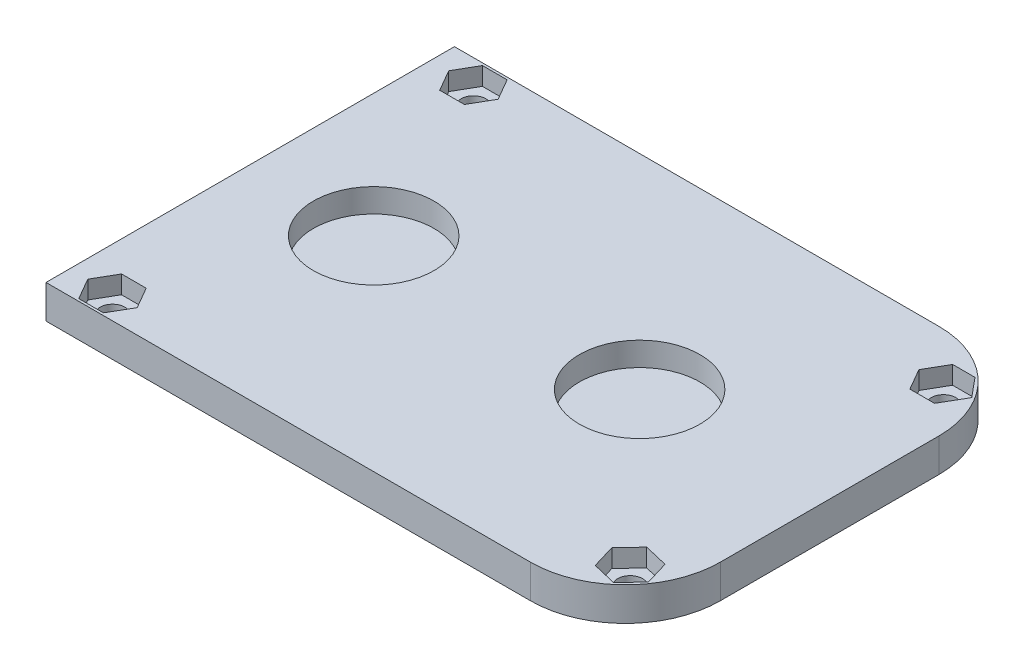
from build123d import *

# Parameters (mm, degrees)
BOSS_EXTRUDE1_DEPTH = 4.476
CUT_EXTRUDE1_DEPTH  = 2.413
SKETCH4_R           = 1.65
CUT_EXTRUDE2_DEPTH  = 5.476
CUT_EXTRUDE3_DEPTH  = 3.175
SKETCH6_W           = 16.984037314
SKETCH6_H           = 62.559907231
CUT_EXTRUDE4_DEPTH  = 5.476


with BuildPart() as part:
    # Sketch1 → Boss-Extrude1 (new body)
    with BuildSketch(Plane(origin=(0, 0, 0), x_dir=(1, 0, 0), z_dir=(0, 1, 0))):
        with BuildLine():
            Line((-8.37964191, 28.608687003), (58.93035809, 28.608687003))
            ThreePointArc((58.93035809, 28.608687003), (67.910614211, 24.888943124), (71.63035809, 15.908687003))
            Line((71.63035809, 15.908687003), (71.63035809, -13.301312997))
            ThreePointArc((71.63035809, -13.301312997), (67.910614211, -22.281569118), (58.93035809, -26.001312997))
            Line((58.93035809, -26.001312997), (-8.37964191, -26.001312997))
            ThreePointArc((-8.37964191, -26.001312997), (-12.86976997, -24.141441058), (-14.72964191, -19.651312997))
            Line((-14.72964191, -19.651312997), (-14.72964191, 22.258687003))
            ThreePointArc((-14.72964191, 22.258687003), (-12.86976997, 26.748815063), (-8.37964191, 28.608687003))
        make_face()
    extrude(amount=BOSS_EXTRUDE1_DEPTH)

    # Sketch2 → Cut-Extrude1 (cut)
    with BuildSketch(Plane(origin=(0, 4.476, 0), x_dir=(1, 0, 0), z_dir=(0, 1, 0))):
        Polygon((64.265579696, 19.401187003), (67.565136484, 19.401187003), (69.384674475, 22.552719249), (67.257293816, 25.116187003), (64.265579696, 25.116187003), (62.615801302, 22.258687003), align=None)
        Polygon((69.12572552, -20.413294604), (68.180437233, -17.252044051), (64.970069804, -16.490062445), (62.704990661, -18.889331391), (63.650278947, -22.050581944), (66.860646377, -22.81256355), align=None)
        Polygon((-1.774420304, 22.576187003), (1.525136484, 22.576187003), (3.174914879, 25.433687003), (1.525136484, 28.291187003), (-1.774420304, 28.291187003), (-3.424198698, 25.433687003), align=None)
        Polygon((-1.774420304, -25.683812997), (1.525136484, -25.683812997), (3.174914879, -22.826312997), (1.525136484, -19.968812997), (-1.774420304, -19.968812997), (-3.424198698, -22.826312997), align=None)
    extrude(amount=-CUT_EXTRUDE1_DEPTH, mode=Mode.SUBTRACT)

    # Sketch4 → Cut-Extrude2 (cut, through all)
    with BuildSketch(Plane(origin=(0, 4.476, 0), x_dir=(1, 0, 0), z_dir=(0, 1, 0))):
        with Locations((-0.12464191, 25.433687003)):
            Circle(SKETCH4_R)
        with Locations((-0.12464191, -22.826312997)):
            Circle(SKETCH4_R)
        with Locations((65.91535809, -19.651312997)):
            Circle(SKETCH4_R)
        with Locations((65.91535809, 22.258687003)):
            Circle(SKETCH4_R)
    extrude(amount=-CUT_EXTRUDE2_DEPTH, mode=Mode.SUBTRACT)

    # Sketch5 → Cut-Extrude3 (cut)
    with BuildSketch(Plane(origin=(0, 4.476, 0), x_dir=(1, 0, 0), z_dir=(0, 1, 0))):
        with BuildLine():
            ThreePointArc((18.73485809, 1.303687003), (10.67035809, 9.368187003), (2.60585809, 1.303687003))
            Line((2.60585809, 1.303687003), (18.73485809, 1.303687003))
        make_face()
        with BuildLine():
            Line((18.73485809, 1.303687003), (2.60585809, 1.303687003))
            ThreePointArc((2.60585809, 1.303687003), (10.67035809, -6.760812997), (18.73485809, 1.303687003))
        make_face()
        with BuildLine():
            ThreePointArc((54.29485809, 1.303687003), (46.23035809, 9.368187003), (38.16585809, 1.303687003))
            Line((38.16585809, 1.303687003), (54.29485809, 1.303687003))
        make_face()
        with BuildLine():
            Line((54.29485809, 1.303687003), (38.16585809, 1.303687003))
            ThreePointArc((38.16585809, 1.303687003), (46.23035809, -6.760812997), (54.29485809, 1.303687003))
        make_face()
    extrude(amount=-CUT_EXTRUDE3_DEPTH, mode=Mode.SUBTRACT)

    # Sketch6 → Cut-Extrude4 (cut, through all)
    with BuildSketch(Plane(origin=(0, 4.476, 0), x_dir=(1, 0, 0), z_dir=(0, 1, 0))):
        with Locations((-14.331660567, 1.51751481)):
            Rectangle(SKETCH6_W, SKETCH6_H)
    extrude(amount=-CUT_EXTRUDE4_DEPTH, mode=Mode.SUBTRACT)


solid = part.part
